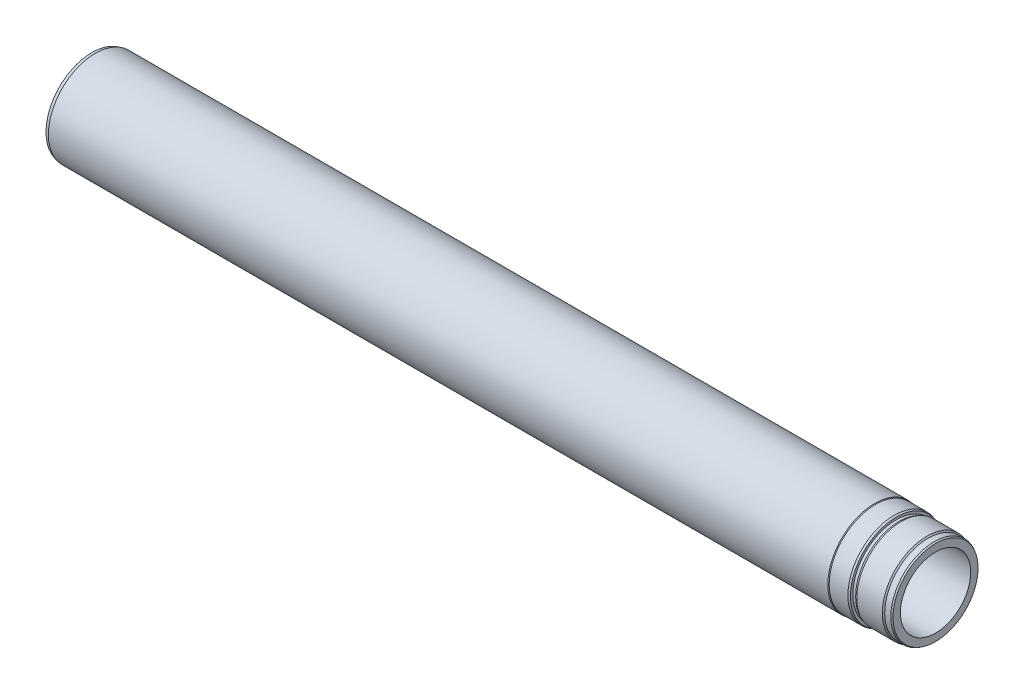
from build123d import *


with BuildPart() as part:
    # Sketch1 → Base-Revolve (revolve)
    with BuildSketch(Plane.XY):
        Polygon((0, 37.5), (0, 45.383974596), (-1.5, 46.25), (-8, 46.25), (-9.25, 47.5), (-36.546736868, 47.5), (-39, 46.25), (-42, 46.25), (-42, 48.772059531), (-44, 49.5), (-64, 49.5), (-64.866025404, 50), (-896.5, 50), (-900, 49.062177826), (-900, 41.75), (-898.5, 40.25), (-878, 40.25), (-875.692042299, 38.9175), (-825, 38.9175), (-816.960958021, 37.5), align=None)
    revolve(axis=Axis((-900, 0, 0), (1, 0, 0)))


solid = part.part
